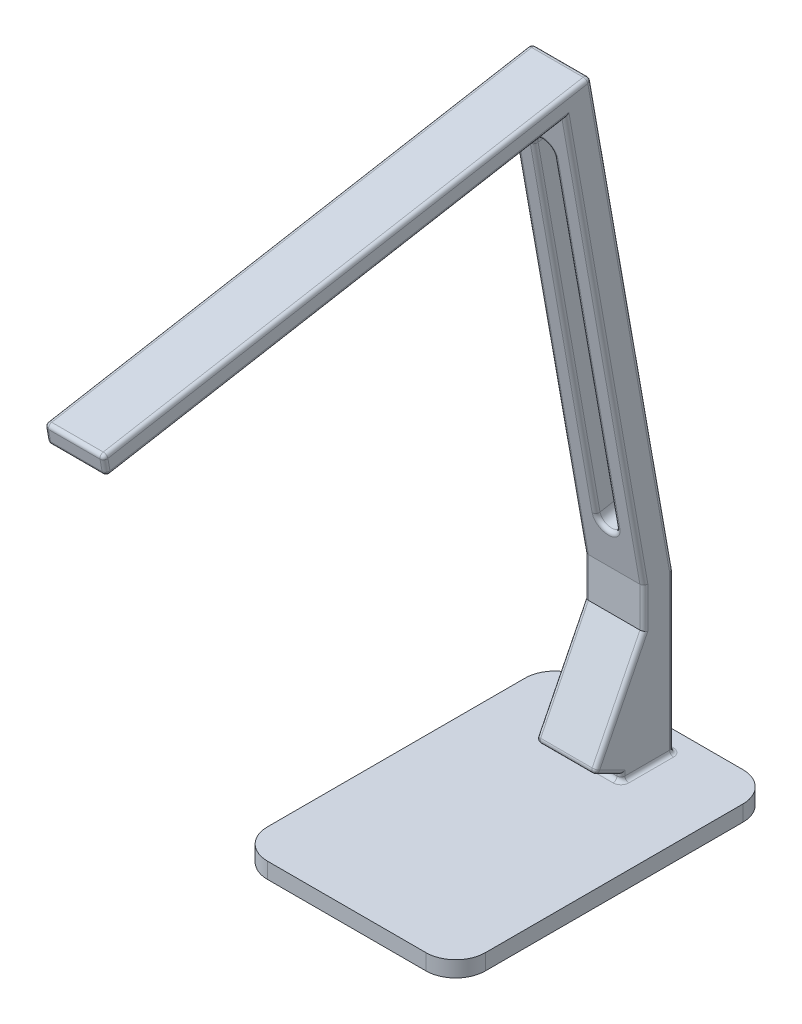
from build123d import *

# Parameters (mm, degrees)
SKETCH1_W           = 139.7
SKETCH1_H           = 203.2
BOSS_EXTRUDE1_DEPTH = 10.16
SKETCH2_W           = 38.1
SKETCH2_H           = 50.8
BOSS_EXTRUDE2_DEPTH = 76.2
CUT_EXTRUDE1_DEPTH  = 89.9
SKETCH4_W           = 38.1
SKETCH4_H           = 19.05
BOSS_EXTRUDE3_DEPTH = 25.4
BOSS_EXTRUDE4_DEPTH = 38.1
CUT_EXTRUDE2_DEPTH  = 82.219688091
SKETCH7_W           = 38.1
SKETCH7_H           = 12.7
BOSS_EXTRUDE5_DEPTH = 317.5
FILLET1_R           = 2.54
FILLET2_R           = 19.05


with BuildPart() as part:
    # Sketch1 → Boss-Extrude1 (new body)
    with BuildSketch(Plane(origin=(0, 0, 0), x_dir=(1, 0, 0), z_dir=(0, 1, 0))):
        Rectangle(SKETCH1_W, SKETCH1_H)
    extrude(amount=BOSS_EXTRUDE1_DEPTH)

    # Sketch2 → Boss-Extrude2 (add)
    with BuildSketch(Plane(origin=(0, 10.16, 0), x_dir=(1, 0, 0), z_dir=(0, 1, 0))):
        with Locations((0, 63.5)):
            Rectangle(SKETCH2_W, SKETCH2_H)
    extrude(amount=BOSS_EXTRUDE2_DEPTH)

    # Sketch3 → Cut-Extrude1 (cut, through all)
    with BuildSketch(Plane.ZY.offset(19.05)):
        Polygon((-38.1, 10.16), (-38.1, 22.86), (-55.138837989, 14.340581006), (-55.138837989, 10.16), align=None)
        Polygon((-38.1, 86.36), (-69.85, 86.36), (-38.1, 22.86), align=None)
    extrude(amount=-CUT_EXTRUDE1_DEPTH, mode=Mode.SUBTRACT)

    # Sketch4 → Boss-Extrude3 (add)
    with BuildSketch(Plane(origin=(0, 86.36, 0), x_dir=(1, 0, 0), z_dir=(0, 1, 0))):
        with Locations((0, 79.375)):
            Rectangle(SKETCH4_W, SKETCH4_H)
    extrude(amount=BOSS_EXTRUDE3_DEPTH)

    # Sketch5 → Boss-Extrude4 (add)
    with BuildSketch(Plane.ZY.offset(19.05)):
        Polygon((-88.9, 111.76), (-38.177367303, 399.422344655), (-19.701795091, 396.16460279), (-69.85, 111.76), align=None)
    extrude(amount=-BOSS_EXTRUDE4_DEPTH)

    # Sketch6 → Cut-Extrude2 (cut, through all)
    with BuildSketch(Plane(origin=(0, 15.315029856, -86.85585039), x_dir=(1, 0, 0), z_dir=(0, -0.173648178, 0.984807753))):
        with BuildLine():
            Line((6.35, 356.628790374), (6.35, 128.028790374))
            ThreePointArc((6.35, 128.028790374), (0, 121.678790374), (-6.35, 128.028790374))
            Line((-6.35, 128.028790374), (-6.35, 356.628790374))
            ThreePointArc((-6.35, 356.628790374), (0, 362.978790374), (6.35, 356.628790374))
        make_face()
    extrude(amount=-CUT_EXTRUDE2_DEPTH, mode=Mode.SUBTRACT)

    # Sketch7 → Boss-Extrude5 (add)
    with BuildSketch(Plane(origin=(0, 18.572771721, -105.331422603), x_dir=(1, 0, 0), z_dir=(0, -0.173648178, 0.984807753))):
        with Locations((0, 393.074791482)):
            Rectangle(SKETCH7_W, SKETCH7_H)
    extrude(amount=BOSS_EXTRUDE5_DEPTH)

    # Fillet1
    fillet1_edges = [part.edges().sort_by_distance(p)[0] for p in [
        (-19.05, 384.362754913, 120.366195344),
        (-19.05, 370.226825518, 127.398649594),
        (19.05, 370.226825518, 127.398649594),
        (0, 411.929403118, -35.972035447),
        (19.05, 384.362754913, 120.366195344),
        (-19.05, 350.542577477, 275.601760206),
        (0, 344.289048246, 274.499094278),
        (19.05, 350.542577477, 275.601760206),
        (0, 356.796106709, 276.704426134),
        (0, 10.16, -88.9),
        (19.05, 60.96, -88.9),
        (-19.05, 10.16, -72.019418994),
        (-19.05, 60.96, -88.9),
        (0, 22.86, -38.1),
        (19.05, 10.16, -72.019418994),
        (19.05, 12.250290503, -55.138837989),
        (0, 10.16, -55.138837989),
        (19.05, 18.600290503, -46.619418994),
        (-19.05, 18.600290503, -46.619418994),
        (-19.05, 12.250290503, -55.138837989),
        (19.05, 54.61, -53.975),
        (-19.05, 54.61, -53.975),
        (-19.05, 99.06, -69.85),
        (19.05, 99.06, -69.85),
        (0, 111.76, -88.9),
        (-19.05, 253.962301395, -44.775897545),
        (-19.05, 261.844701559, -62.436017724),
        (19.05, 261.844701559, -62.436017724),
        (19.05, 253.962301395, -44.775897545),
        (0, 376.037098661, -42.300817123),
        (6.35, 257.22004326, -63.251469758),
        (0, 138.402987859, -84.202122394),
        (-6.35, 257.22004326, -63.251469758),
        (0, 372.779356796, -23.82524491),
        (-6.35, 253.962301395, -44.775897545),
        (0, 135.145245994, -65.726550181),
        (6.35, 253.962301395, -44.775897545),
    ]]
    fillet(fillet1_edges, radius=FILLET1_R)

    # Fillet2
    fillet2_edges = [part.edges().sort_by_distance(p)[0] for p in [
        (69.85, 5.08, 101.6),
        (-69.85, 5.08, 101.6),
        (-69.85, 5.08, -101.6),
        (69.85, 5.08, -101.6),
    ]]
    fillet(fillet2_edges, radius=FILLET2_R)


solid = part.part
